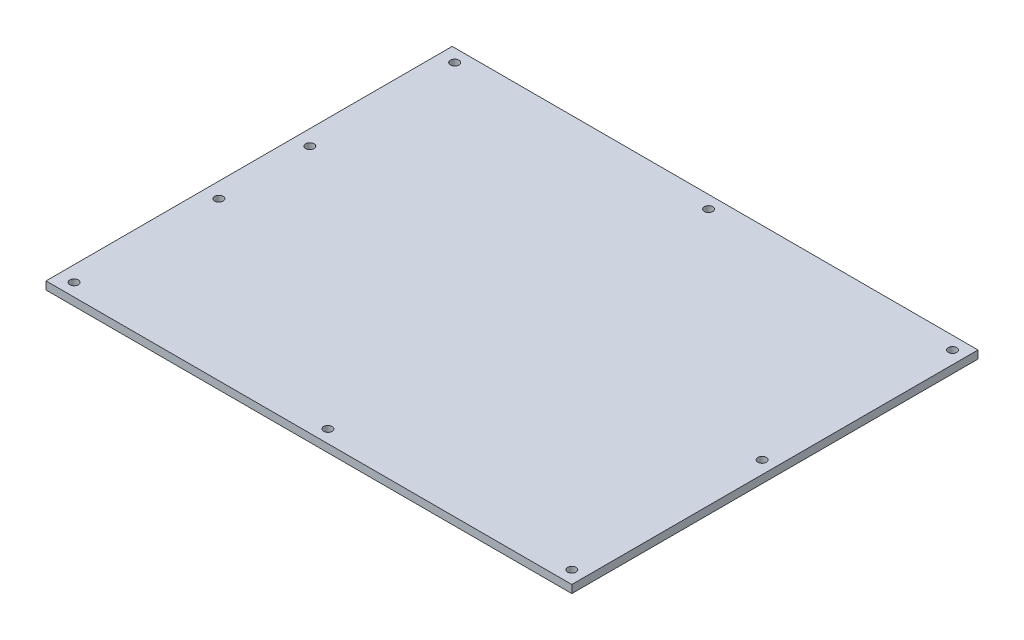
from build123d import *

# Parameters (mm, degrees)
SKETCH1_W           = 211
SKETCH1_H           = 163
BOSS_EXTRUDE1_DEPTH = 3.175
SKETCH2_R           = 1.7
CUT_EXTRUDE1_DEPTH  = 4.175


with BuildPart() as part:
    # Sketch1 → Boss-Extrude1 (new body)
    with BuildSketch(Plane(origin=(0, 0, 0), x_dir=(1, 0, 0), z_dir=(0, 1, 0))):
        Rectangle(SKETCH1_W, SKETCH1_H)
    extrude(amount=BOSS_EXTRUDE1_DEPTH)

    # Sketch2 → Cut-Extrude1 (cut, through all)
    with BuildSketch(Plane(origin=(0, 0, 0), x_dir=(-1, 0, 0), z_dir=(0, -1, 0))):
        with Locations((99.375, -76.375)):
            Circle(SKETCH2_R)
        with Locations((-2.5, -76.375)):
            Circle(SKETCH2_R)
        with Locations((-100.375, -76.375)):
            Circle(SKETCH2_R)
        with Locations((-100.375, 0)):
            Circle(SKETCH2_R)
        with Locations((-100.375, 76.375)):
            Circle(SKETCH2_R)
        with Locations((-2.5, 76.375)):
            Circle(SKETCH2_R)
        with Locations((99.375, 76.375)):
            Circle(SKETCH2_R)
        with Locations((99.375, 18.25)):
            Circle(SKETCH2_R)
        with Locations((99.375, -18.25)):
            Circle(SKETCH2_R)
    extrude(amount=-CUT_EXTRUDE1_DEPTH, mode=Mode.SUBTRACT)


solid = part.part
